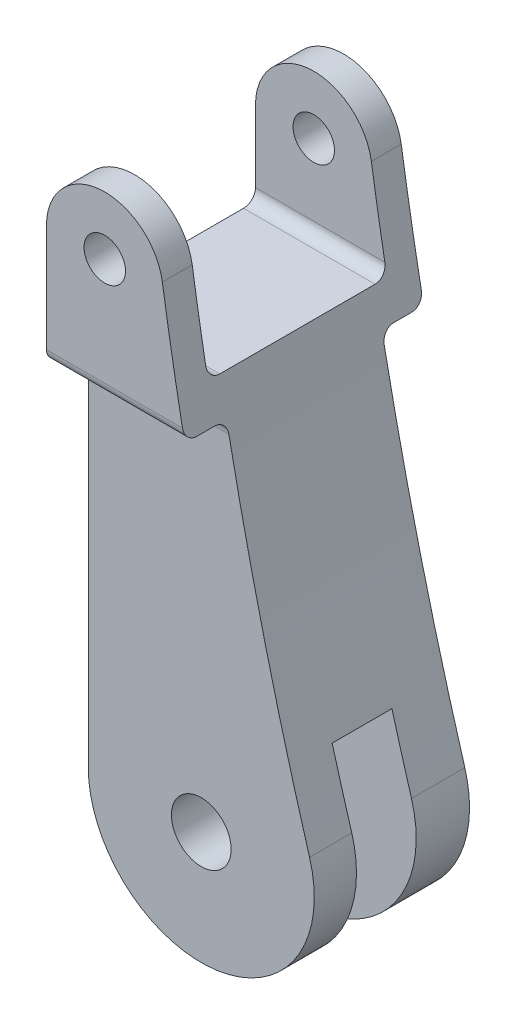
from build123d import *

# Parameters (mm, degrees)
SKETCH_1_R          = 25
SKETCH_1_R_2        = 17.35
EXTRUDE_1_DEPTH     = 100
SKETCH_2_W          = 150
SKETCH_2_H          = 163.350102445
SKETCH_2_W_2        = 100.72153761
SKETCH_2_H_2        = 448.495423617
CUT_EXTRUDE_1_DEPTH = 310
SKETCH_3_W          = 50
SKETCH_3_H          = 358.585755847
CUT_EXTRUDE_2_DEPTH = 310
FILLET_1_R          = 10


with BuildPart() as part:
    # 草图1 → 凸台-拉伸1 (new body, symmetric)
    with BuildSketch(Plane.XY):
        with BuildLine():
            Line((-94.612295013, 0), (-94.612295013, 410))
            ThreePointArc((-94.612295013, 410), (-49.57442783, 458.65476705), (2.407637637, 417.501872778))
            ThreePointArc((2.407637637, 417.501872778), (39.895934897, 220.789706501), (90.654933023, 27.07710262))
            ThreePointArc((90.654933023, 27.07710262), (13.682381008, -93.617727048), (-94.612295013, 0))
        make_face()
        Circle(SKETCH_1_R, mode=Mode.SUBTRACT)
        with Locations((-45.812295013, 410)):
            Circle(SKETCH_1_R_2, mode=Mode.SUBTRACT)
    extrude(amount=EXTRUDE_1_DEPTH, both=True)

    # 草图2 → 切除-拉伸1 (cut)
    with BuildSketch(Plane.ZY.offset(94.612295013)):
        with Locations((0, 421.675051222)):
            Rectangle(SKETCH_2_W, SKETCH_2_H)
        with Locations((-115.360768805, 85.752288191)):
            Rectangle(SKETCH_2_W_2, SKETCH_2_H_2)
        with Locations((115.360768805, 85.752288191)):
            Rectangle(SKETCH_2_W_2, SKETCH_2_H_2)
    extrude(amount=-CUT_EXTRUDE_1_DEPTH, mode=Mode.SUBTRACT)

    # 草图3 → 切除-拉伸2 (cut)
    with BuildSketch(Plane.ZY.offset(94.612295013)):
        with Locations((4.667160283, -95.292877924)):
            Rectangle(SKETCH_3_W, SKETCH_3_H)
    extrude(amount=-CUT_EXTRUDE_2_DEPTH, mode=Mode.SUBTRACT)

    # 圆角1
    fillet_1_edges = [part.edges().sort_by_distance(p)[0] for p in [
        (-39.543231053, 340, 75),
        (-39.543231053, 340, -75),
        (-36.717696937, 310, -100),
        (-36.717696937, 310, -65),
        (-36.717696937, 310, 100),
        (-36.717696937, 310, 65),
    ]]
    fillet(fillet_1_edges, radius=FILLET_1_R)


solid = part.part
